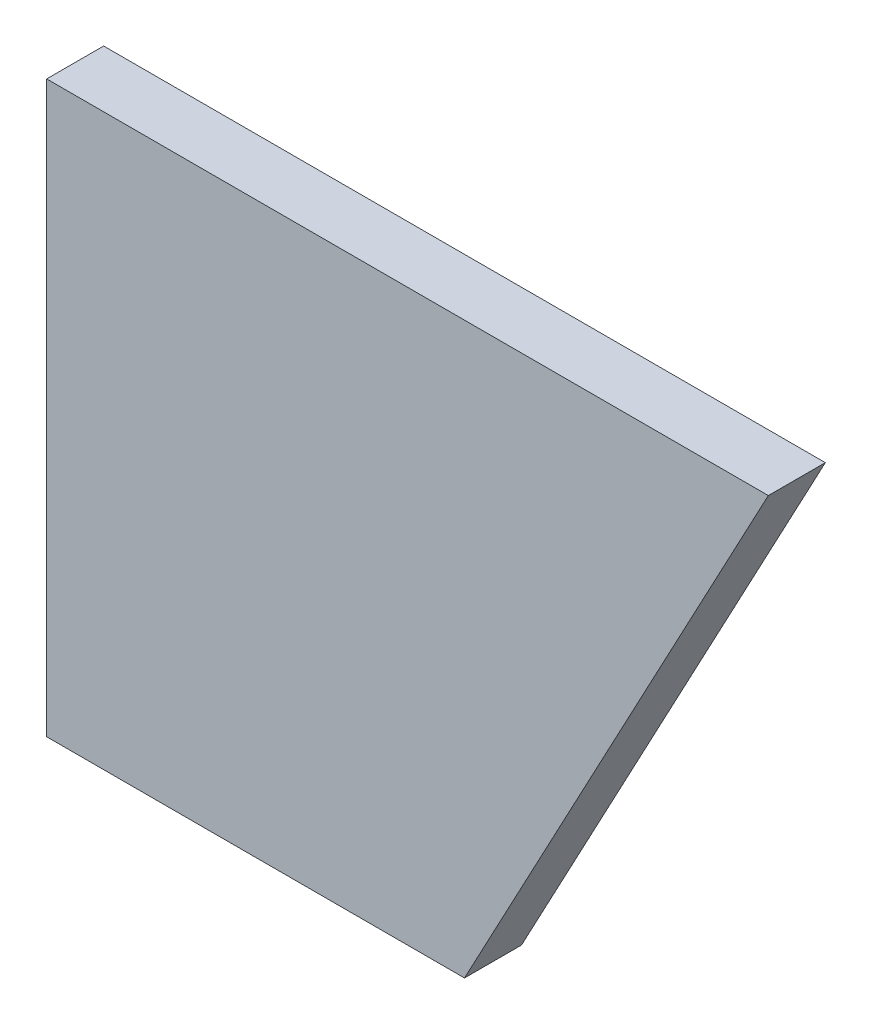
from build123d import *

# Parameters (mm, degrees)
RESSALTO_EXTRUS_O1_DEPTH = 3


with BuildPart() as part:
    # Esboço1 → Ressalto-extrusão1 (new body)
    with BuildSketch(Plane.XY):
        Polygon((0, 0), (22, 0), (38, 30), (0, 30), align=None)
    extrude(amount=RESSALTO_EXTRUS_O1_DEPTH)


solid = part.part
